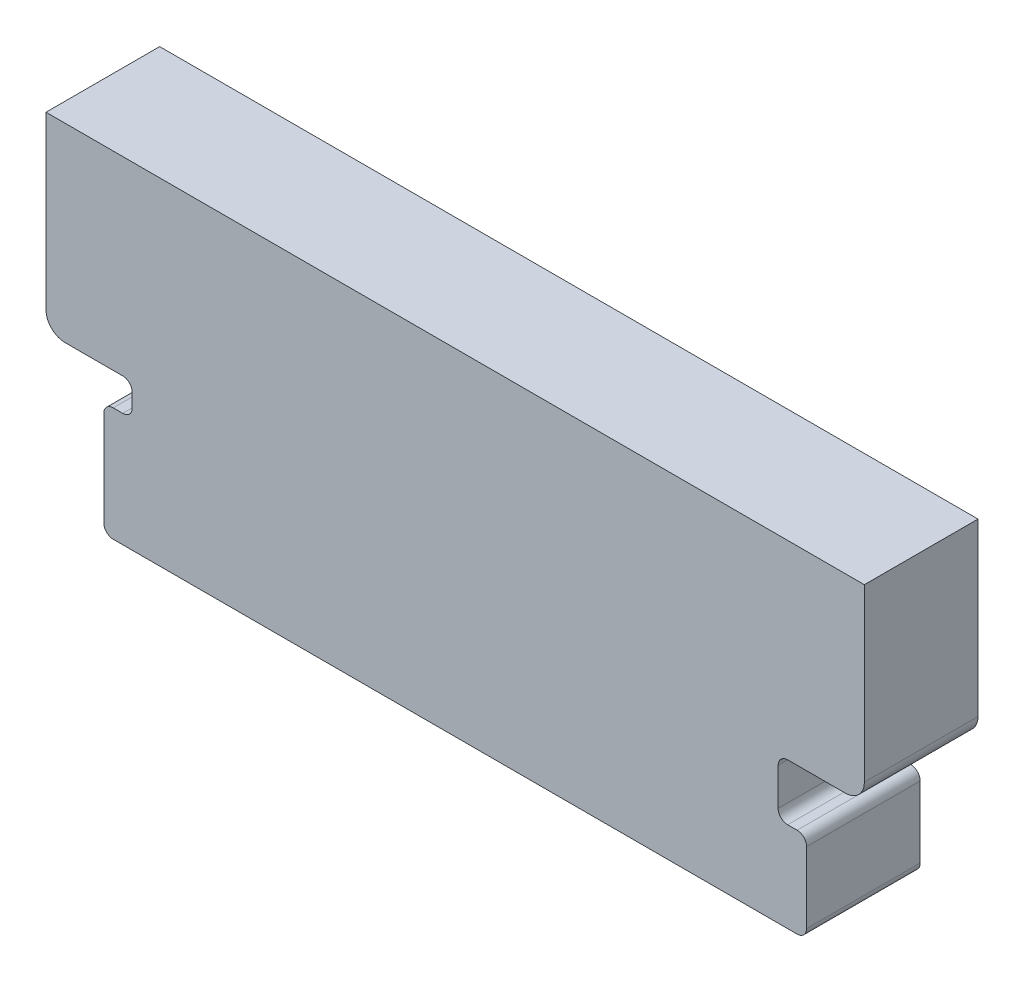
from build123d import *

# Parameters (mm, degrees)
BOSS_EXTRUDE1_DEPTH = 6


with BuildPart() as part:
    # Sketch6 → Boss-Extrude1 (new body)
    with BuildSketch(Plane.XY):
        with BuildLine():
            Line((-18.05, -1.259488518), (18.05, -1.259488518))
            ThreePointArc((18.05, -1.259488518), (18.403553391, -1.113041908), (18.55, -0.759488518))
            Line((18.55, -0.759488518), (18.55, 2.990511482))
            ThreePointArc((18.55, 2.990511482), (18.403553391, 3.344064873), (18.05, 3.490511482))
            Line((18.05, 3.490511482), (17.55, 3.490511482))
            ThreePointArc((17.55, 3.490511482), (17.196446609, 3.636958092), (17.05, 3.990511482))
            Line((17.05, 3.990511482), (17.05, 5.960429817))
            ThreePointArc((17.05, 5.960429817), (17.196446609, 6.313983207), (17.55, 6.460429817))
            Line((17.55, 6.460429817), (20.6, 6.460429817))
            ThreePointArc((20.6, 6.460429817), (21.307106781, 6.753323035), (21.6, 7.460429817))
            Line((21.6, 7.460429817), (21.6, 16.490511482))
            Line((21.6, 16.490511482), (-21.6, 16.490511482))
            Line((-21.6, 16.490511482), (-21.6, 7.460429817))
            ThreePointArc((-21.6, 7.460429817), (-21.307106781, 6.753323035), (-20.6, 6.460429817))
            Line((-20.6, 6.460429817), (-17.55, 6.460429817))
            ThreePointArc((-17.55, 6.460429817), (-17.196446609, 6.313983207), (-17.05, 5.960429817))
            Line((-17.05, 5.960429817), (-17.05, 5.25))
            ThreePointArc((-17.05, 5.25), (-17.196446609, 4.896446609), (-17.55, 4.75))
            Line((-17.55, 4.75), (-18.05, 4.75))
            ThreePointArc((-18.05, 4.75), (-18.403553391, 4.603553391), (-18.55, 4.25))
            Line((-18.55, 4.25), (-18.55, -0.759488518))
            ThreePointArc((-18.55, -0.759488518), (-18.403553391, -1.113041908), (-18.05, -1.259488518))
        make_face()
    extrude(amount=BOSS_EXTRUDE1_DEPTH)


solid = part.part
